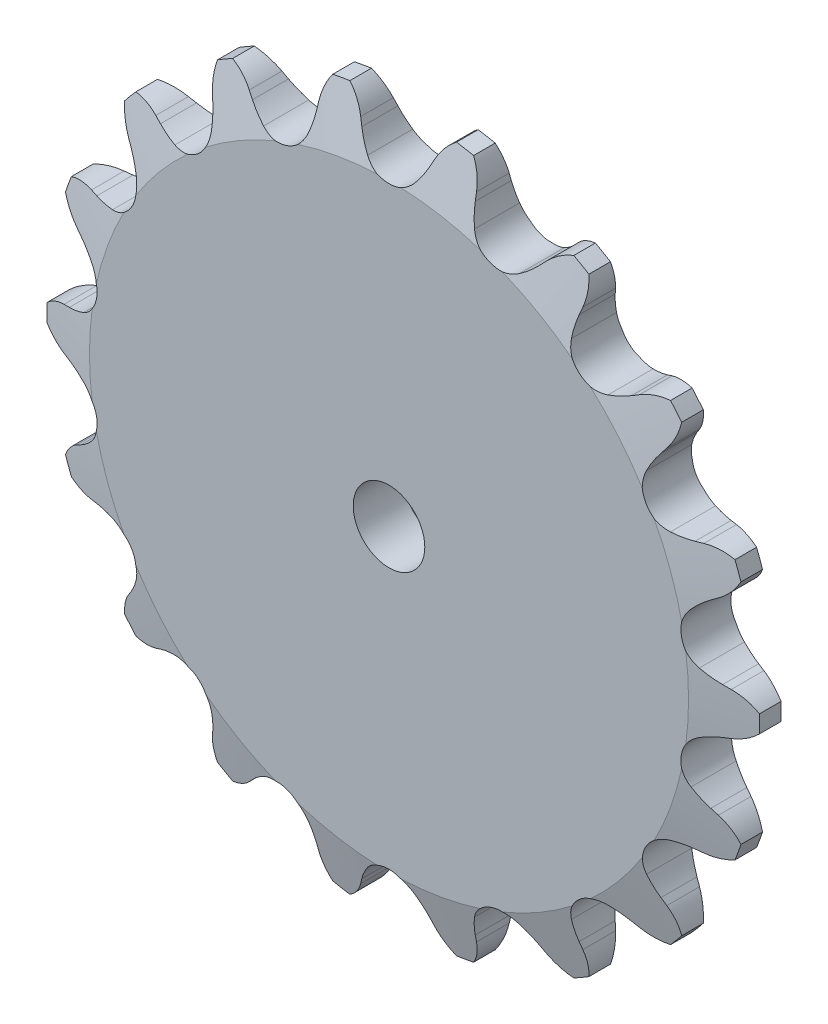
from build123d import *

# Parameters (mm, degrees)
TOOTH_CUT_NUMBER_OF_TEETH_18_DEPTH = 29.19349073
TOOTH_PATTERN_18_18_COUNT          = 18
CUT_EXTRUDE1_DEPTH                 = 29.035736303
CUT_EXTRUDE1_DEPTH_BACK            = 29.035736303
SKETCH4_R                          = 2


with BuildPart() as part:
    # Sprocket-BaseSketch → 25 _04C_ ANSI _ISO_ Chain Number_ 1.440i (revolve)
    with BuildSketch(Plane(origin=(0, 0, 0), x_dir=(0, 0, -1), z_dir=(1, 0, 0))):
        Polygon((1.397, 0), (1.397, 16.736319777), (0.60325, 19.911319777), (-0.60325, 19.911319777), (-1.397, 16.736319777), (-1.397, 0), align=None)
    revolve(axis=Axis((0, 0, -5.588), (0, 0, 1)))

    # Tooth-Sketch → Tooth-Cut_ Number of teeth_ 18 (cut, symmetric)
    with BuildSketch(Plane.XY):
        with BuildLine():
            Line((1.908645709, 18.196215131), (2.066224101, 18.559583724))
            ThreePointArc((2.066224101, 18.559583724), (3.065556725, 19.747030253), (4.552569281, 20.191427162))
            ThreePointArc((4.552569281, 20.191427162), (0, 20.69829988), (-4.552569281, 20.191427162))
            ThreePointArc((-4.552569281, 20.191427162), (-3.065556725, 19.747030253), (-2.066224101, 18.559583724))
            Line((-2.066224101, 18.559583724), (-1.908645709, 18.196215131))
            ThreePointArc((-1.908645709, 18.196215131), (-1.651424634, 17.695000021), (-1.331431851, 17.231336472))
            ThreePointArc((-1.331431851, 17.231336472), (0, 16.586741284), (1.331431851, 17.231336472))
            ThreePointArc((1.331431851, 17.231336472), (1.651424634, 17.695000021), (1.908645709, 18.196215131))
        make_face()
    tooth_cut_number_of_teeth_18 = extrude(amount=TOOTH_CUT_NUMBER_OF_TEETH_18_DEPTH, both=True, mode=Mode.SUBTRACT)

    # Tooth Pattern_ 18 _ 18: Tooth-Cut_ Number of teeth_ 18 ×18 about axis
    tooth_pattern_18_18_axis = Axis((0, 0, -88.99), (0, 0, 1))
    for i in range(1, TOOTH_PATTERN_18_18_COUNT):
        add(tooth_cut_number_of_teeth_18.rotate(tooth_pattern_18_18_axis, i * 360 / TOOTH_PATTERN_18_18_COUNT), mode=Mode.SUBTRACT)

    # Sketch4 → Cut-Extrude1 (cut, two sides: drawn at the far end of the back side and taken through both)
    with BuildSketch(Plane.XY.offset(-CUT_EXTRUDE1_DEPTH_BACK)):
        Circle(SKETCH4_R)
    extrude(amount=CUT_EXTRUDE1_DEPTH + CUT_EXTRUDE1_DEPTH_BACK, mode=Mode.SUBTRACT)


solid = part.part
